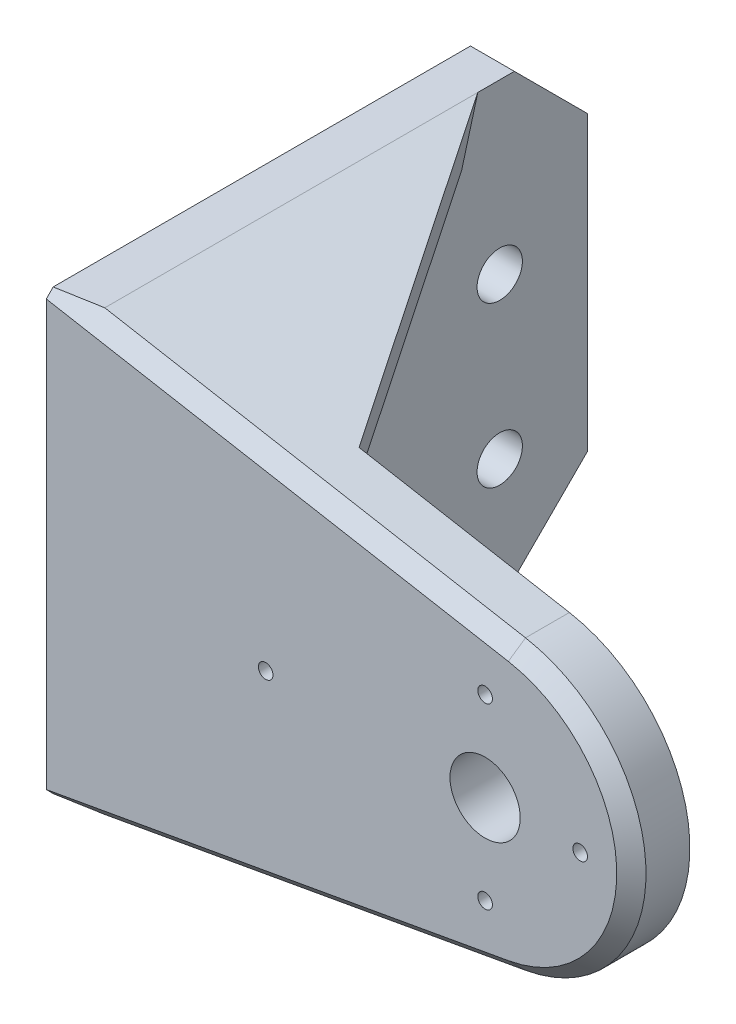
from build123d import *

# Parameters (mm, degrees)
BOSS_EXTRUDE1_DEPTH = 4
SKETCH3_W           = 3
SKETCH3_H           = 30
BOSS_EXTRUDE2_DEPTH = 30
BOSS_EXTRUDE3_DEPTH = 4
CHAMFER1_SIZE       = 5
CHAMFER2_SIZE       = 5
CHAMFER3_SIZE       = 1
CUT_EXTRUDE3_REACH  = 53.88
SKETCH6_R           = 1.55
CUT_EXTRUDE4_REACH  = 45.819
SKETCH7_R           = 2.4
CUT_EXTRUDE5_REACH  = 45.819
SKETCH8_R           = 0.5


with BuildPart() as part:
    # Sketch1 → Boss-Extrude1 (new body)
    with BuildSketch(Plane.XY):
        with BuildLine():
            Line((-21.444, -9.44375), (7.320666414, -4.286816212))
            ThreePointArc((7.320666414, -4.286816212), (15.556, 5.55625), (7.320666414, 15.399316212))
            Line((7.320666414, 15.399316212), (-21.444, 20.55625))
            Line((-21.444, 20.55625), (-24.444, 20.55625))
            Line((-24.444, 20.55625), (-24.444, -9.44375))
            Line((-24.444, -9.44375), (-21.444, -9.44375))
        make_face()
    extrude(amount=BOSS_EXTRUDE1_DEPTH)

    # Sketch3 → Boss-Extrude2 (add)
    with BuildSketch(Plane(origin=(0, 0, 0), x_dir=(-1, 0, 0), z_dir=(0, 0, -1))):
        with Locations((22.944, 5.55625)):
            Rectangle(SKETCH3_W, SKETCH3_H)
    extrude(amount=BOSS_EXTRUDE2_DEPTH)

    # Sketch4 → Boss-Extrude3 (add)
    with BuildSketch(Plane(origin=(2.902788428, 16.191354052, 0), x_dir=(0.9843066211686926, -0.17646664139001428, 0), z_dir=(0.17646664139001428, 0.9843066211686926, 0))):
        Polygon((-24.734963581, 22.5), (-10.123324385, 0), (-10.123324385, -0.5), (-24.734963581, -0.5), align=None)
    extrude(amount=-BOSS_EXTRUDE3_DEPTH)

    # Chamfer1
    chamfer1_edges = [part.edges().sort_by_distance(p)[0] for p in [
        (-21.444, 3.524362825, 0),
    ]]
    chamfer(chamfer1_edges, length=CHAMFER1_SIZE)

    # Chamfer2
    chamfer2_edges = [part.edges().sort_by_distance(p)[0] for p in [
        (-22.944, -9.44375, -30),
        (-22.944, 20.55625, -30),
    ]]
    chamfer(chamfer2_edges, length=CHAMFER2_SIZE)

    # Chamfer3
    chamfer3_edges = [part.edges().sort_by_distance(p)[0] for p in [
        (-7.061666793, -6.865283106, 4),
        (15.556, 5.55625, 4),
        (-7.061666793, 17.977783106, 4),
    ]]
    chamfer(chamfer3_edges, length=CHAMFER3_SIZE)

    # Sketch6 → Cut-Extrude3 (cut, up to next)
    with BuildSketch(Plane(origin=(-21.444, 0, 0), x_dir=(0, 0, -1), z_dir=(1, 0, 0)), mode=Mode.PRIVATE) as cut_extrude3_sk1:
        with Locations((11, 9.04722098)):
            Circle(SKETCH6_R)
    cut_extrude3_tool1 = extrude(cut_extrude3_sk1.sketch, amount=-CUT_EXTRUDE3_REACH, mode=Mode.PRIVATE) & part.part
    # Sketch6 → Cut-Extrude3 (cut, up to next)
    with BuildSketch(Plane(origin=(-21.444, 0, 0), x_dir=(0, 0, -1), z_dir=(1, 0, 0)), mode=Mode.PRIVATE) as cut_extrude3_sk2:
        with Locations((24, 9.04722098)):
            Circle(SKETCH6_R)
    cut_extrude3_tool2 = extrude(cut_extrude3_sk2.sketch, amount=-CUT_EXTRUDE3_REACH, mode=Mode.PRIVATE) & part.part
    # Sketch6 → Cut-Extrude3 (cut, up to next)
    with BuildSketch(Plane(origin=(-21.444, 0, 0), x_dir=(0, 0, -1), z_dir=(1, 0, 0)), mode=Mode.PRIVATE) as cut_extrude3_sk3:
        with Locations((11, -1.889802378)):
            Circle(SKETCH6_R)
    cut_extrude3_tool3 = extrude(cut_extrude3_sk3.sketch, amount=-CUT_EXTRUDE3_REACH, mode=Mode.PRIVATE) & part.part
    # Sketch6 → Cut-Extrude3 (cut, up to next)
    with BuildSketch(Plane(origin=(-21.444, 0, 0), x_dir=(0, 0, -1), z_dir=(1, 0, 0)), mode=Mode.PRIVATE) as cut_extrude3_sk4:
        with Locations((24, -1.889802378)):
            Circle(SKETCH6_R)
    cut_extrude3_tool4 = extrude(cut_extrude3_sk4.sketch, amount=-CUT_EXTRUDE3_REACH, mode=Mode.PRIVATE) & part.part
    add(cut_extrude3_tool1.solids().sort_by_distance((-21.444, 9.047221, -11))[0], mode=Mode.SUBTRACT)
    add(cut_extrude3_tool2.solids().sort_by_distance((-21.444, 9.047221, -24))[0], mode=Mode.SUBTRACT)
    add(cut_extrude3_tool3.solids().sort_by_distance((-21.444, -1.889802, -11))[0], mode=Mode.SUBTRACT)
    add(cut_extrude3_tool4.solids().sort_by_distance((-21.444, -1.889802, -24))[0], mode=Mode.SUBTRACT)

    # Sketch7 → Cut-Extrude4 (cut, up to next)
    with BuildSketch(Plane(origin=(0, 0, 0), x_dir=(-1, 0, 0), z_dir=(0, 0, -1)), mode=Mode.PRIVATE) as cut_extrude4_sk1:
        with Locations((-5.556, 5.55625)):
            Circle(SKETCH7_R)
    cut_extrude4_tool1 = extrude(cut_extrude4_sk1.sketch, amount=-CUT_EXTRUDE4_REACH, mode=Mode.PRIVATE) & part.part
    add(cut_extrude4_tool1.solids().sort_by_distance((5.556, 5.55625, 0))[0], mode=Mode.SUBTRACT)

    # Sketch8 → Cut-Extrude5 (cut, up to next)
    with BuildSketch(Plane(origin=(0, 0, 0), x_dir=(-1, 0, 0), z_dir=(0, 0, -1)), mode=Mode.PRIVATE) as cut_extrude5_sk1:
        with Locations((9.444, 5.55625)):
            Circle(SKETCH8_R)
    cut_extrude5_tool1 = extrude(cut_extrude5_sk1.sketch, amount=-CUT_EXTRUDE5_REACH, mode=Mode.PRIVATE) & part.part
    # Sketch8 → Cut-Extrude5 (cut, up to next)
    with BuildSketch(Plane(origin=(0, 0, 0), x_dir=(-1, 0, 0), z_dir=(0, 0, -1)), mode=Mode.PRIVATE) as cut_extrude5_sk2:
        with Locations((-5.556, 11.65625)):
            Circle(SKETCH8_R)
    cut_extrude5_tool2 = extrude(cut_extrude5_sk2.sketch, amount=-CUT_EXTRUDE5_REACH, mode=Mode.PRIVATE) & part.part
    # Sketch8 → Cut-Extrude5 (cut, up to next)
    with BuildSketch(Plane(origin=(0, 0, 0), x_dir=(-1, 0, 0), z_dir=(0, 0, -1)), mode=Mode.PRIVATE) as cut_extrude5_sk3:
        with Locations((-5.556, -0.54375)):
            Circle(SKETCH8_R)
    cut_extrude5_tool3 = extrude(cut_extrude5_sk3.sketch, amount=-CUT_EXTRUDE5_REACH, mode=Mode.PRIVATE) & part.part
    # Sketch8 → Cut-Extrude5 (cut, up to next)
    with BuildSketch(Plane(origin=(0, 0, 0), x_dir=(-1, 0, 0), z_dir=(0, 0, -1)), mode=Mode.PRIVATE) as cut_extrude5_sk4:
        with Locations((-12.056, 5.55625)):
            Circle(SKETCH8_R)
    cut_extrude5_tool4 = extrude(cut_extrude5_sk4.sketch, amount=-CUT_EXTRUDE5_REACH, mode=Mode.PRIVATE) & part.part
    add(cut_extrude5_tool1.solids().sort_by_distance((-9.444, 5.55625, 0))[0], mode=Mode.SUBTRACT)
    add(cut_extrude5_tool2.solids().sort_by_distance((5.556, 11.65625, 0))[0], mode=Mode.SUBTRACT)
    add(cut_extrude5_tool3.solids().sort_by_distance((5.556, -0.54375, 0))[0], mode=Mode.SUBTRACT)
    add(cut_extrude5_tool4.solids().sort_by_distance((12.056, 5.55625, 0))[0], mode=Mode.SUBTRACT)


solid = part.part
